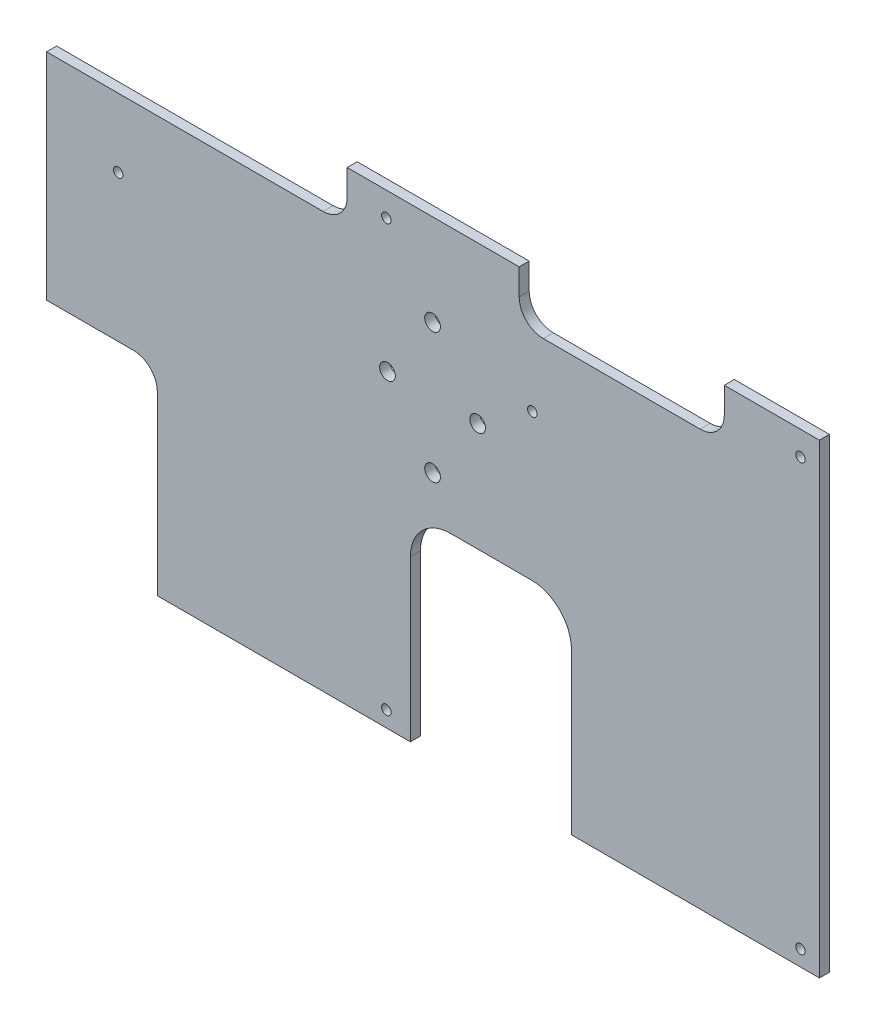
from build123d import *

# Parameters (mm, degrees)
MODEL_R             = 1.5
MODEL_R_2           = 2.4892
BOSS_EXTRUDE1_DEPTH = 3.175


with BuildPart() as part:
    # Model → Boss-Extrude1 (new body)
    with BuildSketch(Plane.XY):
        with BuildLine():
            Line((323.667245607, 226.12499065), (349.307245607, 226.12499065))
            ThreePointArc((349.307245607, 226.12499065), (358.287501728, 222.405246771), (362.007245607, 213.42499065))
            Line((362.007245607, 213.42499065), (362.007245607, 162.55499065))
            Line((362.007245607, 162.55499065), (440.597245607, 162.55499065))
            Line((440.597245607, 162.55499065), (440.597245607, 310.17499065))
            Line((440.597245607, 310.17499065), (410.434211887, 310.17499065))
            Line((410.434211887, 310.17499065), (410.434211887, 301.91999065))
            ThreePointArc((410.434211887, 301.91999065), (408.20236556, 296.531836978), (402.814211887, 294.29999065))
            Line((402.814211887, 294.29999065), (353.054686067, 294.29999065))
            ThreePointArc((353.054686067, 294.29999065), (347.666532395, 296.531836978), (345.434686067, 301.91999065))
            Line((345.434686067, 301.91999065), (345.434686067, 310.17499065))
            Line((345.434686067, 310.17499065), (290.913803272, 310.17499065))
            Line((290.913803272, 310.17499065), (290.913803272, 301.91999065))
            ThreePointArc((290.913803272, 301.91999065), (288.681956945, 296.531836978), (283.293803272, 294.29999065))
            Line((283.293803272, 294.29999065), (195.647245607, 294.29999065))
            Line((195.647245607, 294.29999065), (195.647245607, 226.12499065))
            Line((195.647245607, 226.12499065), (223.137245607, 226.12499065))
            ThreePointArc((223.137245607, 226.12499065), (228.525399279, 223.893144323), (230.757245607, 218.50499065))
            Line((230.757245607, 218.50499065), (230.757245607, 162.55499065))
            Line((230.757245607, 162.55499065), (310.967245607, 162.55499065))
            Line((310.967245607, 162.55499065), (310.967245607, 213.42499065))
            ThreePointArc((310.967245607, 213.42499065), (314.686989486, 222.405246771), (323.667245607, 226.12499065))
        make_face()
        with Locations((303.347245607, 167.55499065)):
            Circle(MODEL_R, mode=Mode.SUBTRACT)
        with Locations((434.597245607, 167.55499065)):
            Circle(MODEL_R, mode=Mode.SUBTRACT)
        with Locations((218.347245607, 272.55499065)):
            Circle(MODEL_R, mode=Mode.SUBTRACT)
        with Locations((317.989745607, 239.93349065)):
            Circle(MODEL_R_2, mode=Mode.SUBTRACT)
        with Locations((303.702245607, 260.57099065)):
            Circle(MODEL_R_2, mode=Mode.SUBTRACT)
        with Locations((317.989745607, 281.20849065)):
            Circle(MODEL_R_2, mode=Mode.SUBTRACT)
        with Locations((303.347245607, 302.55499065)):
            Circle(MODEL_R, mode=Mode.SUBTRACT)
        with Locations((332.277245607, 260.57099065)):
            Circle(MODEL_R_2, mode=Mode.SUBTRACT)
        with Locations((349.597245607, 272.55499065)):
            Circle(MODEL_R, mode=Mode.SUBTRACT)
        with Locations((434.597245607, 302.55499065)):
            Circle(MODEL_R, mode=Mode.SUBTRACT)
    extrude(amount=BOSS_EXTRUDE1_DEPTH)


solid = part.part
